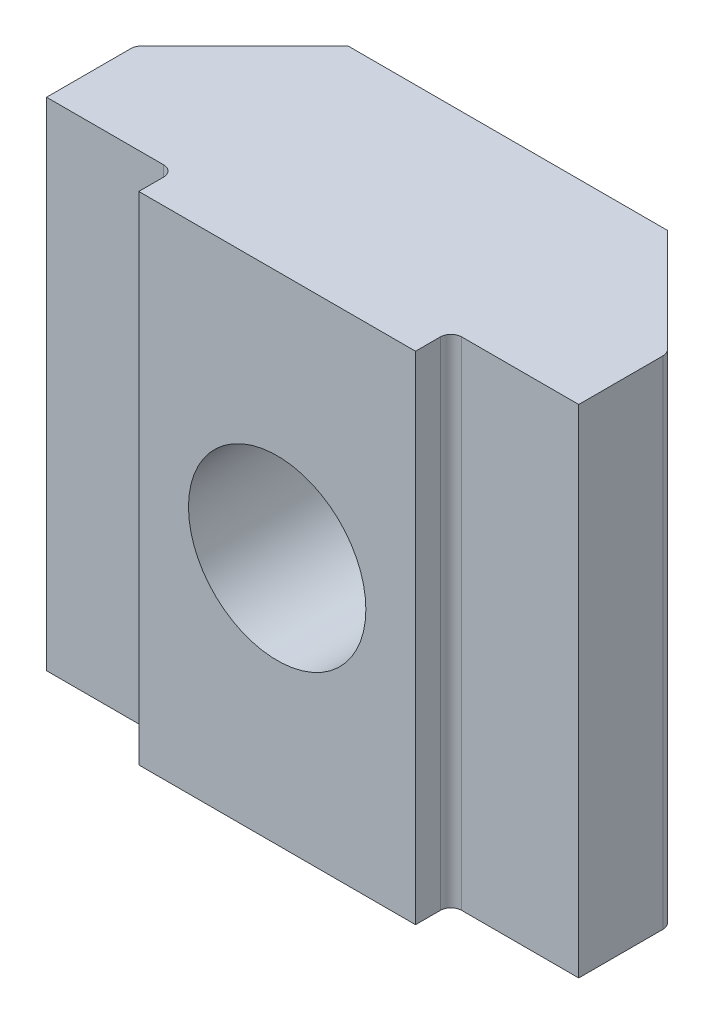
from build123d import *

# Parameters (mm, degrees)
SKETCH1_W      = 15
SKETCH1_H      = 14
EXTRUDE1_DEPTH = 5.5
SKETCH2_W      = 7.8
SKETCH2_H      = 14
EXTRUDE2_DEPTH = 1
SKETCH7_W      = 2.5
SKETCH7_H      = 6.500025
CHAMFER1_SIZE  = 3
FILLET1_R      = 0.3


with BuildPart() as part:
    # Sketch1 → Extrude1 (new body)
    with BuildSketch(Plane.XY):
        Rectangle(SKETCH1_W, SKETCH1_H)
    extrude(amount=-EXTRUDE1_DEPTH)

    # Sketch2 → Extrude2 (add)
    with BuildSketch(Plane.XY):
        Rectangle(SKETCH2_W, SKETCH2_H)
    extrude(amount=EXTRUDE2_DEPTH)

    # Sketch7 → M6x1.0 Tapped Hole1 (revolve, cut)
    with BuildSketch(Plane(origin=(0, 0, -5.5), x_dir=(0, 1, 0), z_dir=(1, 0, 0))):
        with Locations((1.25, 3.2500125)):
            Rectangle(SKETCH7_W, SKETCH7_H)
    revolve(axis=Axis((0, 0, -11.85), (0, 0, 1)), mode=Mode.SUBTRACT)

    # Chamfer1
    chamfer1_edges = [part.edges().sort_by_distance(p)[0] for p in [
        (7.5, 0, -5.5),
        (-7.5, 0, -5.5),
    ]]
    chamfer(chamfer1_edges, length=CHAMFER1_SIZE)

    # Fillet1
    fillet1_edges = [part.edges().sort_by_distance(p)[0] for p in [
        (-3.9, 0, 0),
        (3.9, 0, 0),
        (7.5, 0, -2.5),
        (-7.5, 0, -2.5),
    ]]
    fillet(fillet1_edges, radius=FILLET1_R)


solid = part.part
